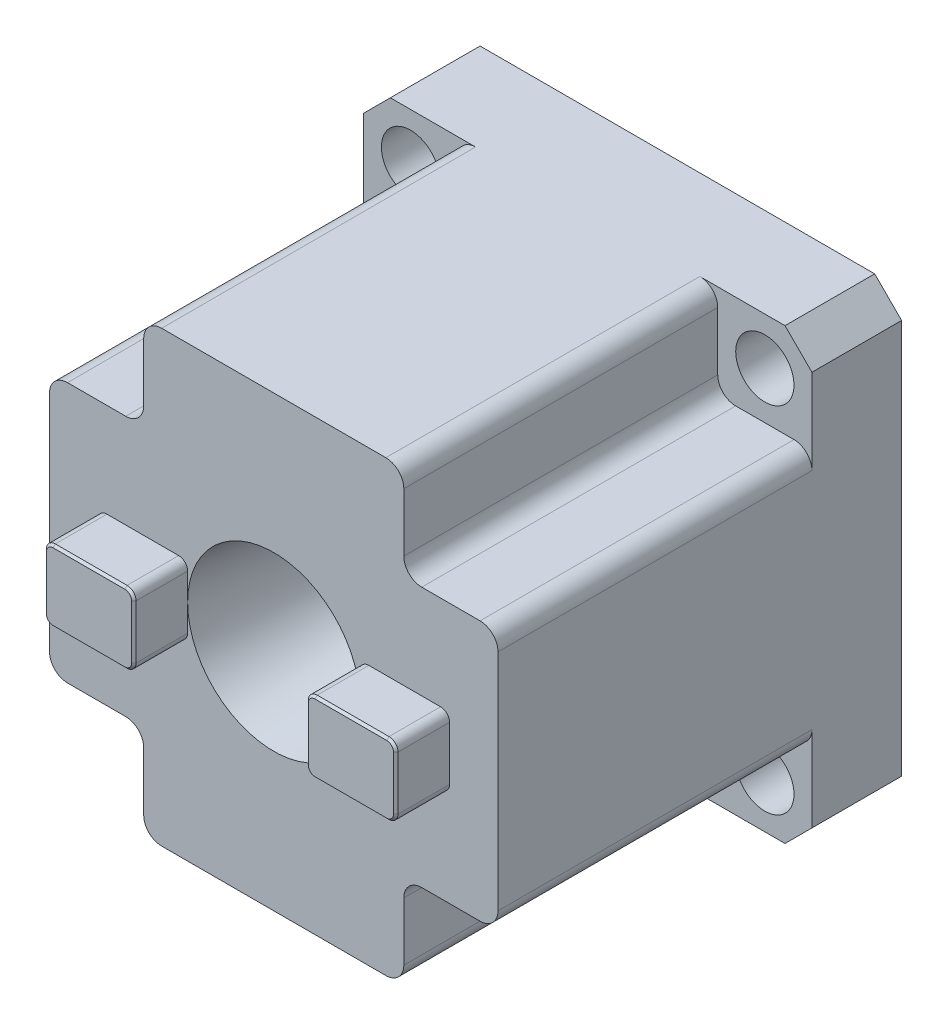
from build123d import *

# Parameters (mm, degrees)
SKETCH_1_W          = 50
SKETCH_1_H          = 50
EXTRUDE_1_DEPTH     = 45
SKETCH_4_W          = 10.5
SKETCH_4_H          = 10.5
CUT_EXTRUDE_1_DEPTH = 35
FILLET_1_R          = 2
CHAMFER_1_SIZE      = 3
SKETCH_5_R          = 3.25
CUT_EXTRUDE_2_DEPTH = 11
SKETCH_7_W          = 10
SKETCH_7_H          = 8
EXTRUDE_4_DEPTH     = 6
FILLET_2_R          = 1
CHAMFER_2_SIZE      = 0.25


with BuildPart() as part:
    # 草图1 → 凸台-拉伸1 (new body)
    with BuildSketch(Plane.XY):
        with Locations((25, -25)):
            Rectangle(SKETCH_1_W, SKETCH_1_H)
    extrude(amount=EXTRUDE_1_DEPTH)

    # 草图4 → 切除-拉伸1 (cut)
    with BuildSketch(Plane.XY.offset(45)):
        with Locations((5.25, -5.25)):
            Rectangle(SKETCH_4_W, SKETCH_4_H)
        with Locations((44.75, -5.25)):
            Rectangle(SKETCH_4_W, SKETCH_4_H)
        with Locations((44.75, -44.75)):
            Rectangle(SKETCH_4_W, SKETCH_4_H)
        with Locations((5.25, -44.75)):
            Rectangle(SKETCH_4_W, SKETCH_4_H)
    extrude(amount=-CUT_EXTRUDE_1_DEPTH, mode=Mode.SUBTRACT)

    # 圆角1
    fillet_1_edges = [part.edges().sort_by_distance(p)[0] for p in [
        (0, -39.5, 27.5),
        (10.5, -39.5, 27.5),
        (10.5, -50, 27.5),
        (39.5, -50, 27.5),
        (39.5, -39.5, 27.5),
        (50, -39.5, 27.5),
        (50, -10.5, 27.5),
        (39.5, -10.5, 27.5),
        (39.5, 0, 27.5),
        (0, -10.5, 27.5),
        (10.5, 0, 27.5),
        (10.5, -10.5, 27.5),
    ]]
    fillet(fillet_1_edges, radius=FILLET_1_R)

    # 倒角1
    chamfer_1_edges = [part.edges().sort_by_distance(p)[0] for p in [
        (0, 0, 5),
        (50, 0, 5),
        (50, -50, 5),
        (0, -50, 5),
    ]]
    chamfer(chamfer_1_edges, length=CHAMFER_1_SIZE)

    # 草图5 → 切除-拉伸2 (cut, through all)
    with BuildSketch(Plane.XY.offset(10)):
        with Locations((5.25, -5.25)):
            Circle(SKETCH_5_R)
        with Locations((44.75, -5.25)):
            Circle(SKETCH_5_R)
        with Locations((44.75, -44.75)):
            Circle(SKETCH_5_R)
        with Locations((5.25, -44.75)):
            Circle(SKETCH_5_R)
    extrude(amount=-CUT_EXTRUDE_2_DEPTH, mode=Mode.SUBTRACT)

    # 草图6 → 切除-旋转1 (revolve, cut)
    with BuildSketch(Plane(origin=(25, 0, 0), x_dir=(0, 0, -1), z_dir=(1, 0, 0))):
        Polygon((-45, -15.4), (-45, -25), (0, -25), (0, -19), (-20.314285805, -19), align=None)
    revolve(axis=Axis((25, -25, 0), (0, 0, 1)), mode=Mode.SUBTRACT)

    # 草图7 → 凸台-拉伸4 (add)
    with BuildSketch(Plane.XY.offset(45)):
        with Locations((39.6, -25)):
            Rectangle(SKETCH_7_W, SKETCH_7_H)
        with Locations((10.4, -25)):
            Rectangle(SKETCH_7_W, SKETCH_7_H)
    extrude(amount=EXTRUDE_4_DEPTH)

    # 圆角2
    fillet_2_edges = [part.edges().sort_by_distance(p)[0] for p in [
        (34.6, -21, 48),
        (34.6, -29, 48),
        (44.6, -29, 48),
        (44.6, -21, 48),
        (15.4, -29, 48),
        (15.4, -21, 48),
        (5.4, -21, 48),
        (5.4, -29, 48),
    ]]
    fillet(fillet_2_edges, radius=FILLET_2_R)

    # 倒角2
    chamfer_2_edges = [part.edges().sort_by_distance(p)[0] for p in [
        (5.4, -25, 51),
        (10.4, -21, 51),
        (15.4, -25, 51),
        (10.4, -29, 51),
        (15.107106781, -21.292893219, 51),
        (15.107106781, -28.707106781, 51),
        (5.692893219, -28.707106781, 51),
        (5.692893219, -21.292893219, 51),
        (34.6, -25, 51),
        (39.6, -21, 51),
        (39.6, -29, 51),
        (44.6, -25, 51),
        (44.307106781, -28.707106781, 51),
        (34.892893219, -28.707106781, 51),
        (44.307106781, -21.292893219, 51),
        (34.892893219, -21.292893219, 51),
    ]]
    chamfer(chamfer_2_edges, length=CHAMFER_2_SIZE)


solid = part.part
